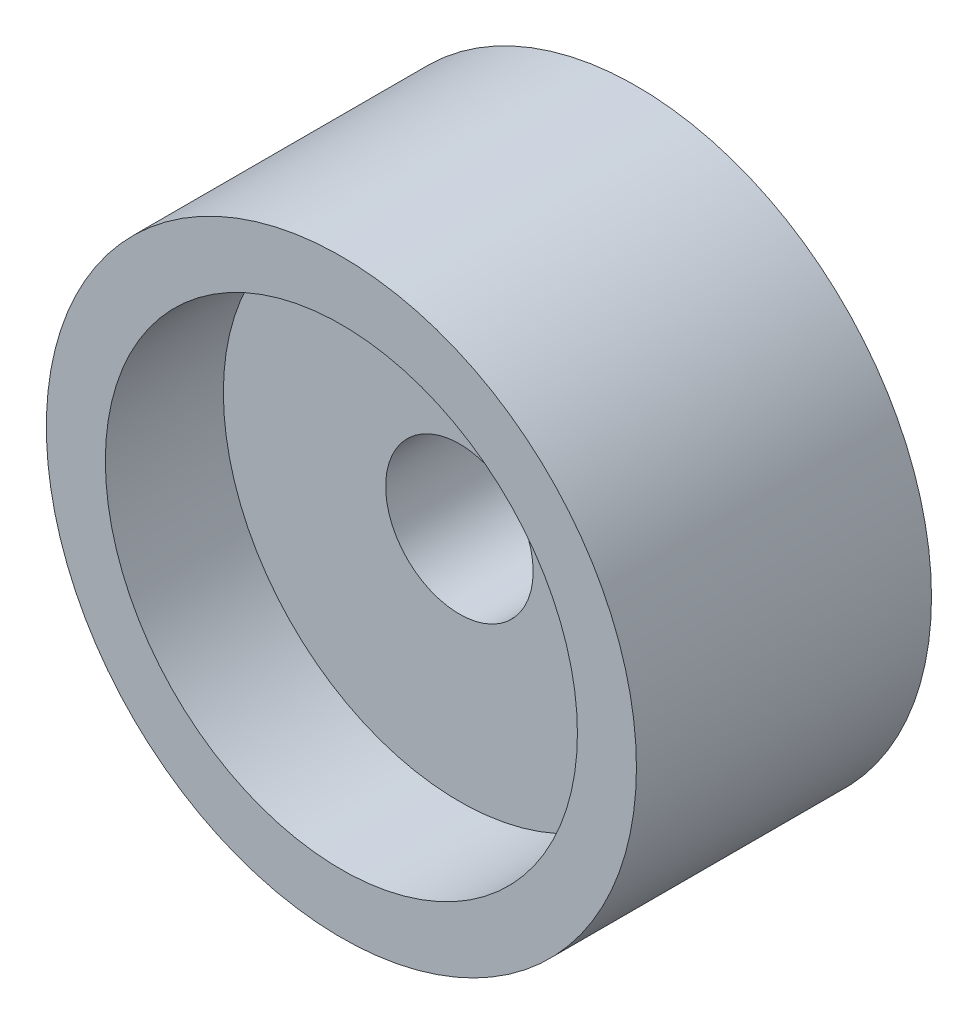
from build123d import *

# Parameters (mm, degrees)
SKETCH1_R           = 5
SKETCH1_R_2         = 4
BOSS_EXTRUDE1_DEPTH = 2
BOSS_EXTRUDE2_START = -3
SKETCH1_3_R         = 5
SKETCH1_3_R_2       = 1.25
BOSS_EXTRUDE2_DEPTH = 3


with BuildPart() as part:
    # Sketch1 → Boss-Extrude1 (new body)
    with BuildSketch(Plane.XY):
        Circle(SKETCH1_R)
        Circle(SKETCH1_R_2, mode=Mode.SUBTRACT)
    extrude(amount=BOSS_EXTRUDE1_DEPTH)

    # Sketch1_3 → Boss-Extrude2 (add)
    with BuildSketch(Plane.XY.offset(BOSS_EXTRUDE2_START)):
        Circle(SKETCH1_3_R)
        Circle(SKETCH1_3_R_2, mode=Mode.SUBTRACT)
    extrude(amount=BOSS_EXTRUDE2_DEPTH)


solid = part.part
